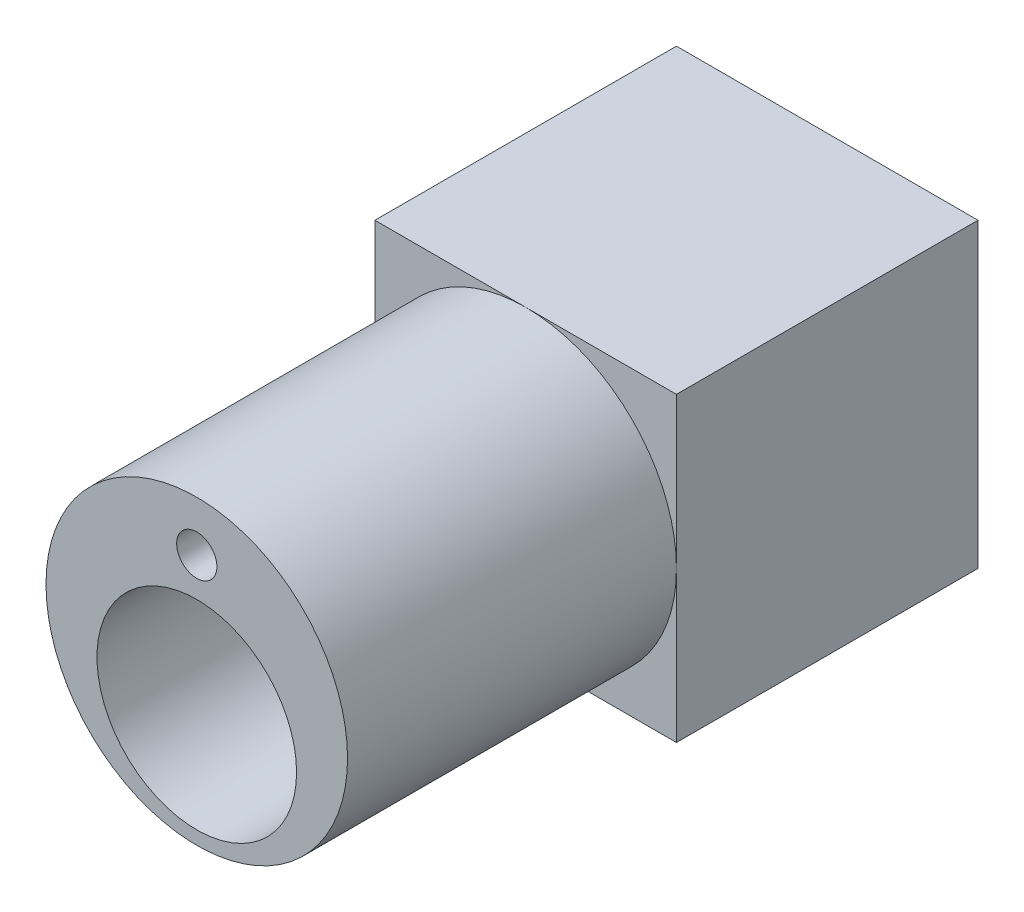
from build123d import *

# Parameters (mm, degrees)
SKETCH1_R           = 28.1
BOSS_EXTRUDE2_DEPTH = 61.3
SKETCH3_R           = 18.6
CUT_EXTRUDE2_DEPTH  = 58.8
SKETCH4_W           = 56.2
SKETCH4_H           = 56.2
BOSS_EXTRUDE3_DEPTH = 56.2
SKETCH5_R           = 16.1
CUT_EXTRUDE4_DEPTH  = 5
SKETCH6_W           = 49.797391422
SKETCH6_H           = 49.779255452
CUT_EXTRUDE5_DEPTH  = 53.7
SKETCH7_R           = 28.1
BOSS_EXTRUDE4_DEPTH = 321.5
CUT_EXTRUDE6_DEPTH  = 10
SKETCH9_R           = 3
CUT_EXTRUDE7_DEPTH  = 1
SKETCH10_R          = 6.025
CUT_EXTRUDE8_DEPTH  = 0.1
SKETCH18_R          = 3.75
CUT_EXTRUDE9_DEPTH  = 100
SKETCH19_R          = 3.75
CUT_EXTRUDE11_DEPTH = 325
SKETCH20_W          = 86.001348001
SKETCH20_H          = 379.283348588
CUT_EXTRUDE16_DEPTH = 171.5


with BuildPart() as part:
    # Sketch1 → Boss-Extrude2 (new body)
    with BuildSketch(Plane.XY):
        Circle(SKETCH1_R)
    extrude(amount=BOSS_EXTRUDE2_DEPTH)

    # Sketch3 → Cut-Extrude2 (cut)
    with BuildSketch(Plane.XY.offset(61.3)):
        with Locations((0, -7)):
            Circle(SKETCH3_R)
    extrude(amount=-CUT_EXTRUDE2_DEPTH, mode=Mode.SUBTRACT)

    # Sketch4 → Boss-Extrude3 (add)
    with BuildSketch(Plane(origin=(0, 0, 0), x_dir=(-1, 0, 0), z_dir=(0, 0, -1))):
        Rectangle(SKETCH4_W, SKETCH4_H)
    extrude(amount=BOSS_EXTRUDE3_DEPTH)

    # Sketch5 → Cut-Extrude4 (cut)
    with BuildSketch(Plane.XY.offset(2.5)):
        with Locations((0, -7)):
            Circle(SKETCH5_R)
    extrude(amount=-CUT_EXTRUDE4_DEPTH, mode=Mode.SUBTRACT)

    # Sketch6 → Cut-Extrude5 (cut)
    with BuildSketch(Plane(origin=(0, 0, -56.2), x_dir=(-1, 0, 0), z_dir=(0, 0, -1))):
        Rectangle(SKETCH6_W, SKETCH6_H)
    extrude(amount=-CUT_EXTRUDE5_DEPTH, mode=Mode.SUBTRACT)

    # Sketch7 → Boss-Extrude4 (add)
    with BuildSketch(Plane(origin=(0, -28.1, 0), x_dir=(-1, 0, 0), z_dir=(0, -1, 0))):
        with Locations(Location((0, 28.1, 0), (0, 0, 90))):
            Circle(SKETCH7_R)
    extrude(amount=BOSS_EXTRUDE4_DEPTH)

    # Sketch8 → Cut-Extrude6 (cut)
    with BuildSketch(Plane(origin=(0, -349.6, 0), x_dir=(-1, 0, 0), z_dir=(0, -1, 0))):
        with BuildLine():
            Line((-1.658312395, 25.832078896), (1.658312395, 25.832078896))
            ThreePointArc((1.658312395, 25.832078896), (3, 28.332078896), (1.658312395, 30.832078896))
            Line((1.658312395, 30.832078896), (-1.658312395, 30.832078896))
            ThreePointArc((-1.658312395, 30.832078896), (-3, 28.332078896), (-1.658312395, 25.832078896))
        make_face()
    extrude(amount=-CUT_EXTRUDE6_DEPTH, mode=Mode.SUBTRACT)

    # Sketch9 → Cut-Extrude7 (cut)
    with BuildSketch(Plane(origin=(0, -349.6, 0), x_dir=(-1, 0, 0), z_dir=(0, -1, 0))):
        with Locations(Location((0, 28.332078896, 0), (0, 0, 90))):
            Circle(SKETCH9_R)
    extrude(amount=-CUT_EXTRUDE7_DEPTH, mode=Mode.SUBTRACT)

    # Sketch10 → Cut-Extrude8 (cut)
    with BuildSketch(Plane(origin=(0, -349.6, 0), x_dir=(-1, 0, 0), z_dir=(0, -1, 0))):
        with Locations(Location((0, 28.332078896, 0), (0, 0, 90))):
            Circle(SKETCH10_R)
    extrude(amount=-CUT_EXTRUDE8_DEPTH, mode=Mode.SUBTRACT)

    # Cut-Sweep4: sweep along a path in Sketch15
    with BuildLine(Plane(origin=(0, -349.6, 0), x_dir=(-1, 0, 0), z_dir=(0, -1, 0))) as cut_sweep4_path:
        ThreePointArc((15, 28.332078896), (0, 43.332078896), (-15, 28.332078896))
    # 3DSketch2 → Cut-Sweep4 (sweep, cut)
    with BuildSketch(Plane(origin=(-15, -349.6, -28.332078896), x_dir=(-0.022748965612757834, 0.999741208795331, 0), z_dir=(0, 0, 1))):
        Polygon((0, 0), (0.170617242, 7.498059066), (329.685319661, 0), (329.514702419, -7.498059066), align=None)
    sweep(path=cut_sweep4_path.line, mode=Mode.SUBTRACT)

    # Sketch18 → Cut-Extrude9 (cut)
    with BuildSketch(Plane.XY.offset(61.3)):
        with Locations((0, 18.75)):
            Circle(SKETCH18_R)
    extrude(amount=-CUT_EXTRUDE9_DEPTH, mode=Mode.SUBTRACT)

    # Sketch19 → Cut-Extrude11 (cut)
    with BuildSketch(Plane(origin=(0, -349.6, 0), x_dir=(-1, 0, 0), z_dir=(0, -1, 0))):
        with Locations((-18.75, 28.332078896)):
            Circle(SKETCH19_R)
        with Locations((18.75, 28.332078896)):
            Circle(SKETCH19_R)
    extrude(amount=-CUT_EXTRUDE11_DEPTH, mode=Mode.SUBTRACT)

    # Sketch20 → Cut-Extrude16 (cut)
    with BuildSketch(Plane(origin=(0, 0, -56.2), x_dir=(-1, 0, 0), z_dir=(0, 0, -1))):
        with Locations((14.900674001, -217.741674294)):
            Rectangle(SKETCH20_W, SKETCH20_H)
    extrude(amount=-CUT_EXTRUDE16_DEPTH, mode=Mode.SUBTRACT)


solid = part.part
